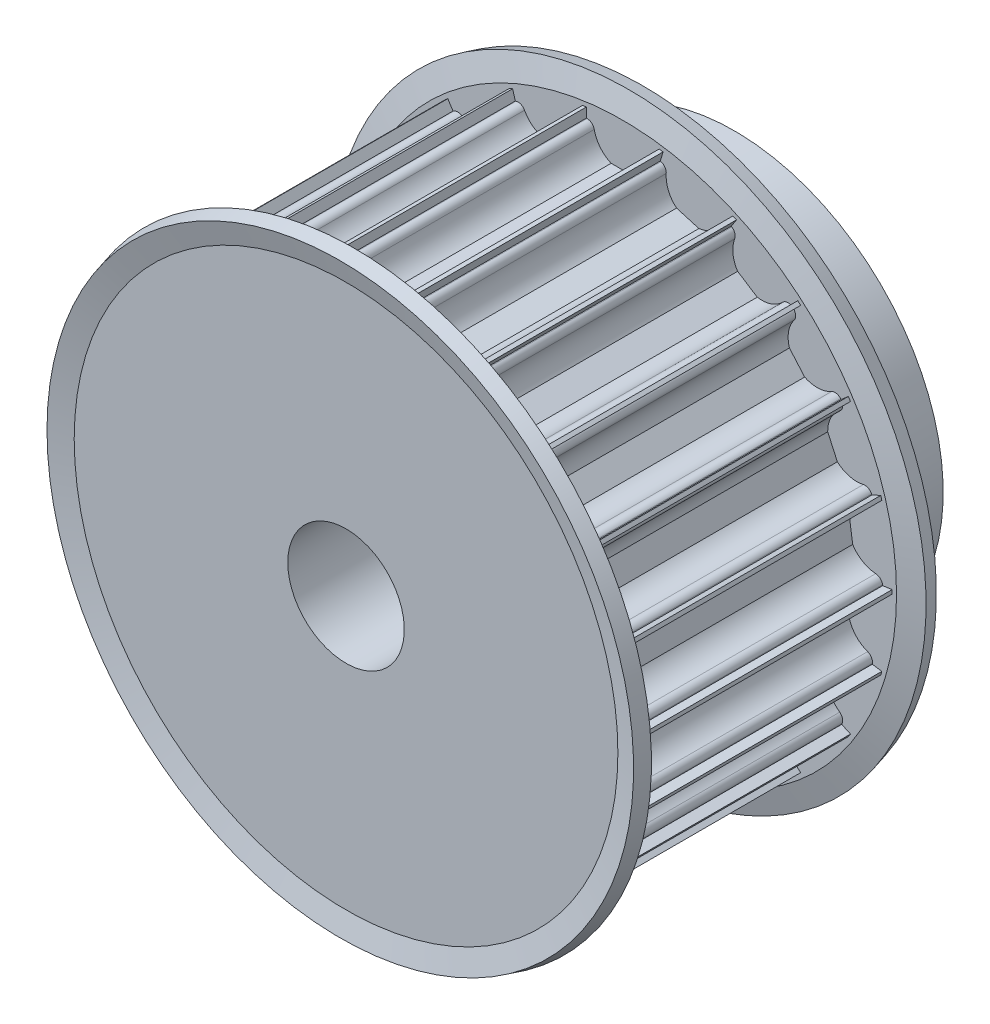
from build123d import *

# Parameters (mm, degrees)
CUT_EXTRUDE1_DEPTH = 41
CIRPATTERN1_COUNT  = 22


with BuildPart() as part:
    # Sketch1 → Revolve1 (revolve)
    with BuildSketch(Plane(origin=(0, 0, 0), x_dir=(0, 0, -1), z_dir=(1, 0, 0))):
        Polygon((0, 6), (0, 27.75), (30, 27.75), (30, 21.5), (40, 21.5), (40, 6), align=None)
    revolve(axis=Axis((0, 0, -88.99), (0, 0, 1)))

    # Sketch2 → Cut-Extrude1 (cut, through all)
    with BuildSketch(Plane.XY):
        with BuildLine():
            Line((3.674234614, 26.5), (3.75, 26.5))
            Line((3.75, 26.5), (3.75, 28.5))
            Line((3.75, 28.5), (-3.75, 28.5))
            Line((-3.75, 28.5), (-3.75, 26.5))
            Line((-3.75, 26.5), (-3.674234614, 26.5))
            ThreePointArc((-3.674234614, 26.5), (-3.199892965, 26.330947502), (-2.939387691, 25.9))
            ThreePointArc((-2.939387691, 25.9), (-2.331759211, 24.612435701), (-1.198957881, 23.75))
            Line((-1.198957881, 23.75), (1.198957881, 23.75))
            ThreePointArc((1.198957881, 23.75), (2.331759211, 24.612435701), (2.939387691, 25.9))
            ThreePointArc((2.939387691, 25.9), (3.199892965, 26.330947502), (3.674234614, 26.5))
        make_face()
    cut_extrude1 = extrude(amount=-CUT_EXTRUDE1_DEPTH, mode=Mode.SUBTRACT)

    # CirPattern1: Cut-Extrude1 ×22 about axis
    cirpattern1_axis = Axis((0, 0, 0), (0, 0, 1))
    for i in range(1, CIRPATTERN1_COUNT):
        add(cut_extrude1.rotate(cirpattern1_axis, i * 360 / CIRPATTERN1_COUNT), mode=Mode.SUBTRACT)

    # Sketch4 → Revolve2 (revolve)
    with BuildSketch(Plane(origin=(0, 0, 0), x_dir=(0, 0, -1), z_dir=(1, 0, 0))):
        Polygon((0, 27.997975423), (0, 23.19545417), (1.5, 23.19545417), (1.5, 28.19545417), (0.856921938, 30.59545417), (-0.591966801, 30.207225602), align=None)
        Polygon((30.591966801, 30.207225602), (29.143078062, 30.59545417), (28.5, 28.19545417), (28.5, 23.19545417), (30, 23.19545417), (30, 27.997975423), align=None)
    revolve(axis=Axis((0, 0, -88.99), (0, 0, 1)))


solid = part.part
